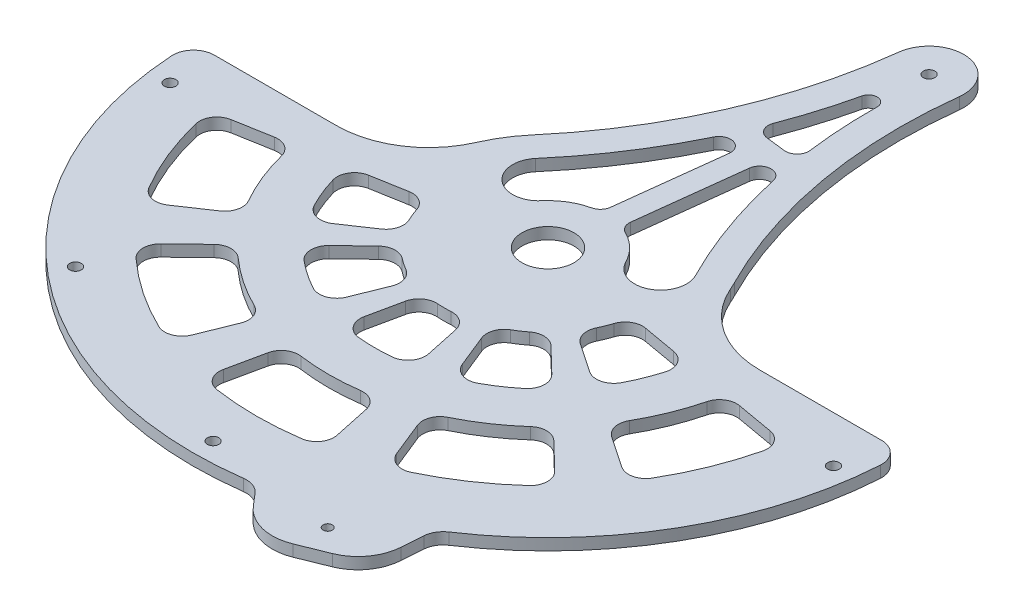
from build123d import *

# Parameters (mm, degrees)
BOSS_EXTRUDE1_DEPTH = 3.175
CUT_EXTRUDE1_DEPTH  = 7.35
CUT_EXTRUDE2_DEPTH  = 3.175
BOSS_EXTRUDE2_DEPTH = 3.175
SKETCH6_R           = 14.2875
CUT_EXTRUDE3_DEPTH  = 7.35
BOSS_EXTRUDE3_DEPTH = 6.35
SKETCH8_R           = 2.54
CUT_EXTRUDE4_DEPTH  = 7.35
SKETCH9_R           = 3.175
CUT_EXTRUDE5_DEPTH  = 7.35
FILLET1_R           = 25.4
FILLET2_R           = 9.525
FILLET4_R           = 11.43
FILLET3_R           = 50.8
SKETCH10_R          = 3.175
BOSS_EXTRUDE4_DEPTH = 6.35
CUT_EXTRUDE8_DEPTH  = 7.35


with BuildPart() as part:
    # Sketch1 → Boss-Extrude1 (new body, symmetric)
    with BuildSketch(Plane(origin=(0, 0, 0), x_dir=(1, 0, 0), z_dir=(0, 1, 0))):
        with BuildLine():
            Line((76.2, 0), (173.0375, 0))
            ThreePointArc((173.0375, 0), (0, -173.0375), (-173.0375, 0))
            Line((-173.0375, 0), (-76.2, 0))
            ThreePointArc((-76.2, 0), (0, 76.2), (76.2, 0))
        make_face()
    extrude(amount=BOSS_EXTRUDE1_DEPTH, both=True)

    # Sketch2 → Cut-Extrude1 (cut, through all)
    with BuildSketch(Plane(origin=(0, 3.175, 0), x_dir=(1, 0, 0), z_dir=(0, 1, 0))):
        with BuildLine():
            Line((-78.965828786, -53.263124056), (-47.379497272, -31.957874433))
            ThreePointArc((-47.379497272, -31.957874433), (-52.988557288, -21.408766814), (-56.281763085, -9.923993354))
            Line((-56.281763085, -9.923993354), (-93.802938474, -16.539988923))
            ThreePointArc((-93.802938474, -16.539988923), (-88.314262147, -35.681278023), (-78.965828786, -53.263124056))
        make_face()
        with BuildLine():
            Line((-60.063484672, -148.662341282), (-45.196285496, -111.864732053))
            ThreePointArc((-45.196285496, -111.864732053), (-67.466623804, -100.023383129), (-86.788346911, -83.810532396))
            Line((-86.788346911, -83.810532396), (-115.337145237, -111.379786473))
            ThreePointArc((-115.337145237, -111.379786473), (-89.65959216, -132.92581179), (-60.063484672, -148.662341282))
        make_face()
        with BuildLine():
            Line((-35.681278023, -88.314262147), (-21.408766814, -52.988557288))
            ThreePointArc((-21.408766814, -52.988557288), (-31.957874433, -47.379497272), (-41.110269589, -39.699725872))
            Line((-41.110269589, -39.699725872), (-68.517115982, -66.166209786))
            ThreePointArc((-68.517115982, -66.166209786), (-53.263124056, -78.965828786), (-35.681278023, -88.314262147))
        make_face()
        with BuildLine():
            Line((-132.92581179, -89.65959216), (-100.023383129, -67.466623804))
            ThreePointArc((-100.023383129, -67.466623804), (-111.864732053, -45.196285496), (-118.817055401, -20.950652636))
            Line((-118.817055401, -20.950652636), (-157.901613099, -27.842314687))
            ThreePointArc((-157.901613099, -27.842314687), (-148.662341282, -60.063484672), (-132.92581179, -89.65959216))
        make_face()
        with BuildLine():
            Line((33.336040726, -156.833740933), (25.084545497, -118.013508029))
            ThreePointArc((25.084545497, -118.013508029), (0, -120.65), (-25.084545497, -118.013508029))
            Line((-25.084545497, -118.013508029), (-33.336040726, -156.833740933))
            ThreePointArc((-33.336040726, -156.833740933), (0, -160.3375), (33.336040726, -156.833740933))
        make_face()
        with BuildLine():
            Line((19.80358855, -93.16855897), (11.88215313, -55.901135382))
            ThreePointArc((11.88215313, -55.901135382), (0, -57.15), (-11.88215313, -55.901135382))
            Line((-11.88215313, -55.901135382), (-19.80358855, -93.16855897))
            ThreePointArc((-19.80358855, -93.16855897), (0, -95.25), (19.80358855, -93.16855897))
        make_face()
        with BuildLine():
            Line((115.337145237, -111.379786473), (86.788346911, -83.810532396))
            ThreePointArc((86.788346911, -83.810532396), (67.466623804, -100.023383129), (45.196285496, -111.864732053))
            Line((45.196285496, -111.864732053), (60.063484672, -148.662341282))
            ThreePointArc((60.063484672, -148.662341282), (89.65959216, -132.92581179), (115.337145237, -111.379786473))
        make_face()
        with BuildLine():
            Line((68.517115982, -66.166209786), (41.110269589, -39.699725872))
            ThreePointArc((41.110269589, -39.699725872), (31.957874433, -47.379497272), (21.408766814, -52.988557288))
            Line((21.408766814, -52.988557288), (35.681278023, -88.314262147))
            ThreePointArc((35.681278023, -88.314262147), (53.263124056, -78.965828786), (68.517115982, -66.166209786))
        make_face()
        with BuildLine():
            Line((157.901613099, -27.842314687), (118.817055401, -20.950652636))
            ThreePointArc((118.817055401, -20.950652636), (111.864732053, -45.196285496), (100.023383129, -67.466623804))
            Line((100.023383129, -67.466623804), (132.92581179, -89.65959216))
            ThreePointArc((132.92581179, -89.65959216), (148.662341282, -60.063484672), (157.901613099, -27.842314687))
        make_face()
        with BuildLine():
            Line((93.802938474, -16.539988923), (56.281763085, -9.923993354))
            ThreePointArc((56.281763085, -9.923993354), (52.988557288, -21.408766814), (47.379497272, -31.957874433))
            Line((47.379497272, -31.957874433), (78.965828786, -53.263124056))
            ThreePointArc((78.965828786, -53.263124056), (88.314262147, -35.681278023), (93.802938474, -16.539988923))
        make_face()
    extrude(amount=-CUT_EXTRUDE1_DEPTH, mode=Mode.SUBTRACT)

    # Sketch5 → Cut-Extrude2 (cut)
    with BuildSketch(Plane(origin=(0, -3.175, 0), x_dir=(1, 0, 0), z_dir=(0, 1, 0))):
        with BuildLine():
            Line((169.8625, 0), (173.0375, 0))
            ThreePointArc((173.0375, 0), (0, -173.0375), (-173.0375, 0))
            Line((-173.0375, 0), (-169.8625, 0))
            ThreePointArc((-169.8625, 0), (0, -169.8625), (169.8625, 0))
        make_face()
    extrude(amount=CUT_EXTRUDE2_DEPTH, mode=Mode.SUBTRACT)

    # Sketch4 → Boss-Extrude2 (add, symmetric)
    with BuildSketch(Plane(origin=(0, 0, 0), x_dir=(1, 0, 0), z_dir=(0, 1, 0))):
        with BuildLine():
            Line((173.0375, 0), (195.2625, 0))
            ThreePointArc((195.2625, 0), (0, -195.2625), (-195.2625, 0))
            Line((-195.2625, 0), (-173.0375, 0))
            ThreePointArc((-173.0375, 0), (0, -173.0375), (173.0375, 0))
        make_face()
    extrude(amount=BOSS_EXTRUDE2_DEPTH, both=True)

    # Sketch6 → Cut-Extrude3 (cut, through all)
    with BuildSketch(Plane(origin=(0, 3.175, 0), x_dir=(1, 0, 0), z_dir=(0, 1, 0))):
        Circle(SKETCH6_R)
    extrude(amount=-CUT_EXTRUDE3_DEPTH, mode=Mode.SUBTRACT)

    # Sketch7 → Boss-Extrude3 (add, through all)
    with BuildSketch(Plane(origin=(0, 3.175, 0), x_dir=(1, 0, 0), z_dir=(0, 1, 0))):
        Polygon((32.206866836, -192.588062026), (53.968732111, -217.988062026), (101.069671923, -198.95804708), (103.466206527, -165.596461355), align=None)
    extrude(amount=-BOSS_EXTRUDE3_DEPTH)

    # Sketch8 → Cut-Extrude4 (cut, through all)
    with BuildSketch(Plane(origin=(0, 3.175, 0), x_dir=(-1, 0, 0), z_dir=(0, 1, 0))):
        with Locations((-72.677869349, 193.782658122)):
            Circle(SKETCH8_R)
    extrude(amount=-CUT_EXTRUDE4_DEPTH, mode=Mode.SUBTRACT)

    # Sketch9 → Cut-Extrude5 (cut, through all)
    with BuildSketch(Plane(origin=(0, 3.175, 0), x_dir=(1, 0, 0), z_dir=(0, 1, 0))):
        with Locations((-182.389864028, -25.4)):
            Circle(SKETCH9_R)
        with Locations((-120.900398056, -138.903982124)):
            Circle(SKETCH9_R)
        with Locations((0, -184.15)):
            Circle(SKETCH9_R)
        with Locations((182.389864028, -25.4)):
            Circle(SKETCH9_R)
    extrude(amount=-CUT_EXTRUDE5_DEPTH, mode=Mode.SUBTRACT)

    # Fillet1
    fillet1_edges = [part.edges().sort_by_distance(p)[0] for p in [
        (53.968732111, 0, 217.988062026),
        (101.069671923, 0, 198.95804708),
    ]]
    fillet(fillet1_edges, radius=FILLET1_R)

    # Fillet2
    fillet2_edges = [part.edges().sort_by_distance(p)[0] for p in [
        (-35.681278023, 0, 88.314262147),
        (-68.517115982, 0, 66.166209786),
        (-41.110269589, 0, 39.699725872),
        (-21.408766814, 0, 52.988557288),
        (33.336040726, 0, 156.833740933),
        (-33.336040726, 0, 156.833740933),
        (-25.084545497, 0, 118.013508029),
        (25.084545497, 0, 118.013508029),
        (-132.92581179, 0, 89.65959216),
        (-157.901613099, 0, 27.842314687),
        (-118.817055401, 0, 20.950652636),
        (-100.023383129, 0, 67.466623804),
        (19.80358855, 0, 93.16855897),
        (-19.80358855, 0, 93.16855897),
        (-11.88215313, 0, 55.901135382),
        (11.88215313, 0, 55.901135382),
        (115.337145237, 0, 111.379786473),
        (60.063484672, 0, 148.662341282),
        (45.196285496, 0, 111.864732053),
        (86.788346911, 0, 83.810532396),
        (93.802938474, 0, 16.539988923),
        (78.965828786, 0, 53.263124056),
        (47.379497272, 0, 31.957874433),
        (56.281763085, 0, 9.923993354),
        (157.901613099, 0, 27.842314687),
        (132.92581179, 0, 89.65959216),
        (100.023383129, 0, 67.466623804),
        (118.817055401, 0, 20.950652636),
        (68.517115982, 0, 66.166209786),
        (35.681278023, 0, 88.314262147),
        (21.408766814, 0, 52.988557288),
        (41.110269589, 0, 39.699725872),
        (-78.965828786, 0, 53.263124056),
        (-93.802938474, 0, 16.539988923),
        (-56.281763085, 0, 9.923993354),
        (-47.379497272, 0, 31.957874433),
        (-60.063484672, 0, 148.662341282),
        (-115.337145237, 0, 111.379786473),
        (-86.788346911, 0, 83.810532396),
        (-45.196285496, 0, 111.864732053),
    ]]
    fillet(fillet2_edges, radius=FILLET2_R)

    # Fillet4
    fillet4_edges = [part.edges().sort_by_distance(p)[0] for p in [
        (-195.2625, 0, 0),
        (195.2625, 0, 0),
        (32.206866836, 0, 192.588062026),
        (103.466206527, 0, 165.596461355),
    ]]
    fillet(fillet4_edges, radius=FILLET4_R)

    # Fillet3
    fillet3_edges = [part.edges().sort_by_distance(p)[0] for p in [
        (-76.2, 0, 0),
        (76.2, 0, 0),
    ]]
    fillet(fillet3_edges, radius=FILLET3_R)

    # Sketch10 → Boss-Extrude4 (add, through all)
    with BuildSketch(Plane(origin=(0, 3.175, 0), x_dir=(1, 0, 0), z_dir=(0, 1, 0))):
        with BuildLine():
            ThreePointArc((67.928946778, 34.526774967), (8.977711779, 75.669284992), (-57.964030941, 49.46322995))
            ThreePointArc((-57.964030941, 49.46322995), (-16.949469571, 114.97748152), (3.307679425, 189.569433618))
            ThreePointArc((3.307679425, 189.569433618), (24.469427945, 206.242321248), (41.142321921, 185.080577729))
            ThreePointArc((41.142321921, 185.080577729), (43.382996969, 107.81939227), (67.928946778, 34.526774967))
        make_face()
        with Locations((22.225, 187.325)):
            Circle(SKETCH10_R, mode=Mode.SUBTRACT)
    extrude(amount=-BOSS_EXTRUDE4_DEPTH)

    # Sketch12 → Cut-Extrude8 (cut, through all)
    with BuildSketch(Plane(origin=(0, 3.175, 0), x_dir=(1, 0, 0), z_dir=(0, 1, 0))):
        with BuildLine():
            Line((-2.07363983, 36.418985679), (4.850539481, 94.779925592))
            ThreePointArc((4.850539481, 94.779925592), (0.333088399, 101.621047974), (-7.165084652, 98.306576579))
            ThreePointArc((-7.165084652, 98.306576579), (-24.649508535, 67.503565311), (-45.888191161, 39.158390377))
            ThreePointArc((-45.888191161, 39.158390377), (-44.294290976, 19.01577896), (-24.151679559, 20.609679146))
            ThreePointArc((-24.151679559, 20.609679146), (-16.406925901, 27.182260437), (-6.98284465, 30.972606939))
            ThreePointArc((-6.98284465, 30.972606939), (-3.662711233, 32.915632241), (-2.07363983, 36.418985679))
        make_face()
        with BuildLine():
            Line((10.537907668, 34.922700382), (17.46208698, 93.283640295))
            ThreePointArc((17.46208698, 93.283640295), (23.454908284, 98.877781208), (29.96934923, 93.900796288))
            ThreePointArc((29.96934923, 93.900796288), (39.760639727, 59.861683314), (53.777082866, 27.333696849))
            ThreePointArc((53.777082866, 27.333696849), (47.514175651, 8.123249021), (28.303727824, 14.386156236))
            ThreePointArc((28.303727824, 14.386156236), (22.311931109, 22.588497741), (14.036401181, 28.478798112))
            ThreePointArc((14.036401181, 28.478798112), (11.263098352, 31.144773477), (10.537907668, 34.922700382))
        make_face()
        with BuildLine():
            Line((7.885230455, 112.532807169), (18.665718923, 111.253766164))
            ThreePointArc((18.665718923, 111.253766164), (23.92581315, 113.09134196), (25.712045825, 118.369092324))
            ThreePointArc((25.712045825, 118.369092324), (23.896495136, 137.880350524), (23.452109252, 157.47085695))
            ThreePointArc((23.452109252, 157.47085695), (19.251080744, 162.259109129), (14.046257475, 158.586805466))
            ThreePointArc((14.046257475, 158.586805466), (9.030141141, 139.644155235), (2.699469968, 121.099397934))
            ThreePointArc((2.699469968, 121.099397934), (3.201149498, 115.550200359), (7.885230455, 112.532807169))
        make_face()
    extrude(amount=-CUT_EXTRUDE8_DEPTH, mode=Mode.SUBTRACT)


solid = part.part
